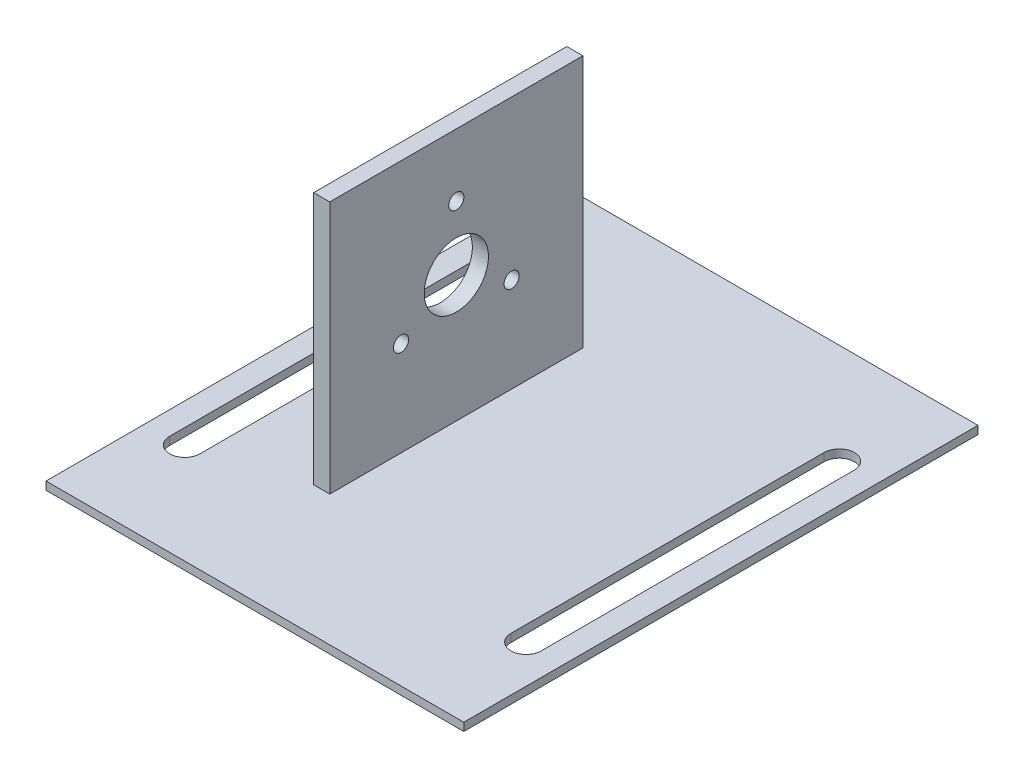
from build123d import *

# Parameters (mm, degrees)
SKETCH1_W                = 165.1
SKETCH1_H                = 203.2
BOSS_EXTRUDE1_DEPTH      = 3.175
CUT_EXTRUDE1_DEPTH       = 4.175
SKETCH3_W                = 6.35
SKETCH3_H                = 100
BOSS_EXTRUDE2_DEPTH      = 100
F_6_0_6_DIAMETER_HOLE1_D = 6
SKETCH4_R                = 12.7
CUT_EXTRUDE2_DEPTH       = 61.549652809


with BuildPart() as part:
    # Sketch1 → Boss-Extrude1 (new body)
    with BuildSketch(Plane(origin=(0, 0, 0), x_dir=(1, 0, 0), z_dir=(0, 1, 0))):
        with Locations((82.55, 101.6)):
            Rectangle(SKETCH1_W, SKETCH1_H)
    extrude(amount=BOSS_EXTRUDE1_DEPTH)

    # Sketch2 → Cut-Extrude1 (cut, through all)
    with BuildSketch(Plane(origin=(0, 3.175, 0), x_dir=(-1, 0, 0), z_dir=(0, 1, 0))):
        with BuildLine():
            Line((-9.113, -39.738854308), (-9.113, -163.461145692))
            ThreePointArc((-9.113, -163.461145692), (-15.113, -169.461145692), (-21.113, -163.461145692))
            Line((-21.113, -163.461145692), (-21.113, -39.738854308))
            ThreePointArc((-21.113, -39.738854308), (-15.113, -33.738854308), (-9.113, -39.738854308))
        make_face()
        with BuildLine():
            Line((-143.987, -39.738854308), (-143.987, -163.461145692))
            ThreePointArc((-143.987, -163.461145692), (-149.987, -169.461145692), (-155.987, -163.461145692))
            Line((-155.987, -163.461145692), (-155.987, -39.738854308))
            ThreePointArc((-155.987, -39.738854308), (-149.987, -33.738854308), (-143.987, -39.738854308))
        make_face()
    extrude(amount=-CUT_EXTRUDE1_DEPTH, mode=Mode.SUBTRACT)

    # Sketch3 → Boss-Extrude2 (add)
    with BuildSketch(Plane(origin=(0, 3.175, 0), x_dir=(-1, 0, 0), z_dir=(0, 1, 0))):
        with Locations((-57.374652809, -101.6)):
            Rectangle(SKETCH3_W, SKETCH3_H)
    extrude(amount=BOSS_EXTRUDE2_DEPTH)

    # Ø6.0 (6) Diameter Hole1 (through all)
    with Locations(Plane(origin=(60.549652809, 78.39827856, -101.6), x_dir=(0, 0, 1), z_dir=(1, 0, 0))):
        with Locations((0, 0), (21.844, 37.83491784), (-21.844, 37.83491784)):
            Hole(F_6_0_6_DIAMETER_HOLE1_D / 2)

    # Sketch4 → Cut-Extrude2 (cut, through all)
    with BuildSketch(Plane(origin=(60.549652809, 0, 0), x_dir=(0, 0, -1), z_dir=(1, 0, 0))):
        with Locations((101.6, 53.175)):
            Circle(SKETCH4_R)
    extrude(amount=-CUT_EXTRUDE2_DEPTH, mode=Mode.SUBTRACT)


solid = part.part
